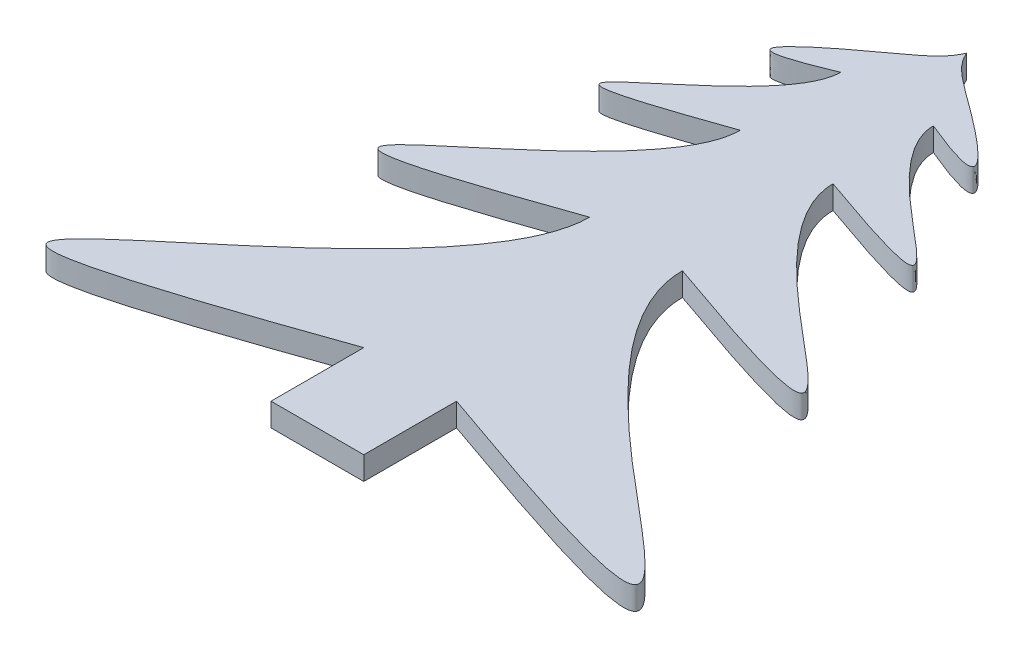
from build123d import *

# Parameters (mm, degrees)
BOSS_EXTRUDE1_DEPTH = 3.175


with BuildPart() as part:
    # Sketch1 → Boss-Extrude1 (new body)
    with BuildSketch(Plane(origin=(0, 0, 0), x_dir=(1, 0, 0), z_dir=(0, 1, 0))):
        with BuildLine():
            Line((-6.35, 12.7), (6.35, 12.7))
            Line((6.35, 12.7), (6.35, 25.4))
            add(Edge.make_bspline(
                [(6.35, 56.328313115), (6.33277042, 33.531169368), (83.156548095, -1.798073983), (6.35, 25.4)],
                knots=[0, 0, 0, 0, 1, 1, 1, 1], degree=3))
            add(Edge.make_bspline(
                [(6.35, 76.947188524), (6.338513613, 61.749092693), (57.554365397, 38.196263793), (6.35, 56.328313115)],
                knots=[0, 0, 0, 0, 1, 1, 1, 1], degree=3))
            add(Edge.make_bspline(
                [(6.35, 90.693105464), (6.342342409, 80.561041577), (40.486243598, 64.859155643), (6.35, 76.947188524)],
                knots=[0, 0, 0, 0, 1, 1, 1, 1], degree=3))
            add(Edge.make_bspline(
                [(0, 101.6), (0.859116351, 99.501641609), (8.04674624, 94.542823282), (20.625145946, 84.684563188), (6.35, 90.693105464)],
                knots=[0, 0, 0, 0, 0.27708829, 1, 1, 1, 1], degree=3))
            add(Edge.make_bspline(
                [(0, 101.6), (-0.859116351, 99.501641609), (-8.04674624, 94.542823282), (-20.625145946, 84.684563188), (-6.35, 90.693105464)],
                knots=[0, 0, 0, 0, 0.27708829, 1, 1, 1, 1], degree=3))
            add(Edge.make_bspline(
                [(-6.35, 90.693105464), (-6.342342409, 80.561041577), (-40.486243598, 64.859155643), (-6.35, 76.947188524)],
                knots=[0, 0, 0, 0, 1, 1, 1, 1], degree=3))
            add(Edge.make_bspline(
                [(-6.35, 76.947188524), (-6.338513613, 61.749092693), (-57.554365397, 38.196263793), (-6.35, 56.328313115)],
                knots=[0, 0, 0, 0, 1, 1, 1, 1], degree=3))
            add(Edge.make_bspline(
                [(-6.35, 56.328313115), (-6.33277042, 33.531169368), (-83.156548095, -1.798073983), (-6.35, 25.4)],
                knots=[0, 0, 0, 0, 1, 1, 1, 1], degree=3))
            Line((-6.35, 25.4), (-6.35, 12.7))
        make_face()
    extrude(amount=-BOSS_EXTRUDE1_DEPTH)


solid = part.part
